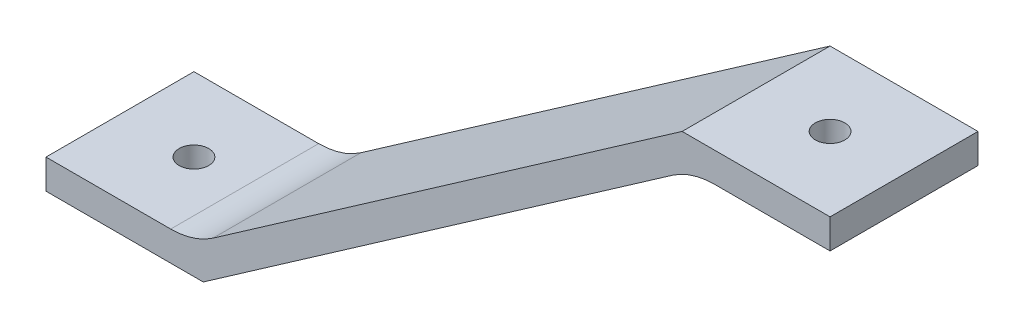
from build123d import *

# Parameters (mm, degrees)
EXTRUDE_1_DEPTH     = 20
SKETCH_13_R         = 2
CUT_EXTRUDE_7_DEPTH = 51
SKETCH_16_R         = 2
CUT_EXTRUDE_8_DEPTH = 51
FILLET_2_R          = 10


with BuildPart() as part:
    # 草图2 → 凸台-拉伸1 (new body)
    with BuildSketch(Plane.XY):
        Polygon((0, 0), (0, -4), (-18.7435877, -4), (-84.7435877, -50), (-106, -50), (-106, -46), (-86, -46), (-20, 0), align=None)
    extrude(amount=EXTRUDE_1_DEPTH)

    # 草图13 → 切除-拉伸7 (cut, through all)
    with BuildSketch(Plane(origin=(0, 0, 0), x_dir=(1, 0, 0), z_dir=(0, 1, 0))):
        with Locations((-10, -10)):
            Circle(SKETCH_13_R)
    extrude(amount=-CUT_EXTRUDE_7_DEPTH, mode=Mode.SUBTRACT)

    # 草图16 → 切除-拉伸8 (cut, through all)
    with BuildSketch(Plane.XZ.offset(50)):
        with Locations((-96, 10)):
            Circle(SKETCH_16_R)
    extrude(amount=-CUT_EXTRUDE_8_DEPTH, mode=Mode.SUBTRACT)

    # 圆角2
    fillet_2_edges = [part.edges().sort_by_distance(p)[0] for p in [
        (-18.7435877, -4, 10),
        (-86, -46, 10),
    ]]
    fillet(fillet_2_edges, radius=FILLET_2_R)


solid = part.part
